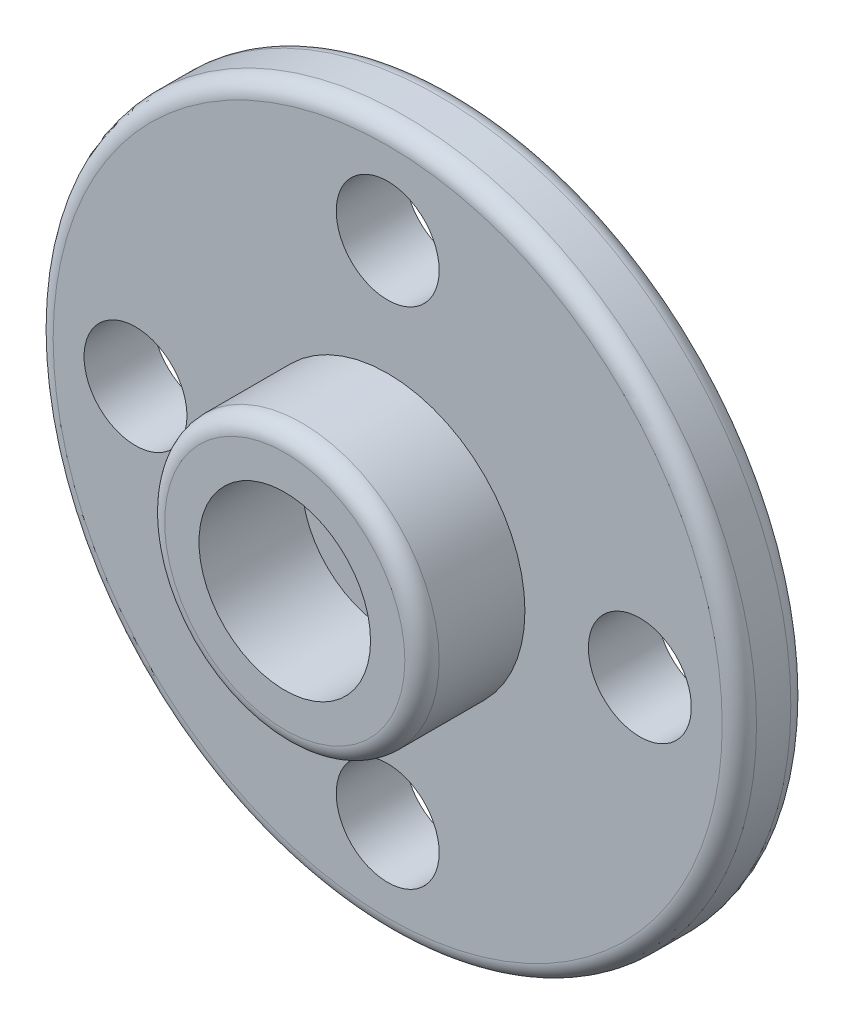
from build123d import *

# Parameters (mm, degrees)
SKETCH_1_R          = 10.25
SKETCH_1_R_2        = 1.5
EXTRUDE_1_DEPTH     = 2
SKETCH_2_R          = 4
EXTRUDE_2_DEPTH     = 3
SKETCH_3_R          = 2.5
CUT_EXTRUDE_1_DEPTH = 3
FILLET_1_R          = 0.5
FILLET_2_R          = 0.5
FILLET_3_R          = 0.5


with BuildPart() as part:
    # 草图1 → 凸台-拉伸1 (new body)
    with BuildSketch(Plane.XY):
        Circle(SKETCH_1_R)
        Circle(SKETCH_1_R_2, mode=Mode.SUBTRACT)
        with Locations((-7.35, 0)):
            Circle(SKETCH_1_R_2, mode=Mode.SUBTRACT)
        with Locations((7.35, 0)):
            Circle(SKETCH_1_R_2, mode=Mode.SUBTRACT)
        with Locations((0, 7.35)):
            Circle(SKETCH_1_R_2, mode=Mode.SUBTRACT)
        with Locations((0, -7.35)):
            Circle(SKETCH_1_R_2, mode=Mode.SUBTRACT)
    extrude(amount=EXTRUDE_1_DEPTH)

    # 草图2 → 凸台-拉伸2 (add)
    with BuildSketch(Plane.XY.offset(2)):
        Circle(SKETCH_2_R)
    extrude(amount=EXTRUDE_2_DEPTH)

    # 草图3 → 切除-拉伸1 (cut)
    with BuildSketch(Plane.XY.offset(5)):
        Circle(SKETCH_3_R)
    extrude(amount=-CUT_EXTRUDE_1_DEPTH, mode=Mode.SUBTRACT)

    # 圆角1
    fillet_1_edges = [part.edges().sort_by_distance(p)[0] for p in [
        (-10.25, 0, 2),
    ]]
    fillet(fillet_1_edges, radius=FILLET_1_R)

    # 圆角2
    fillet_2_edges = [part.edges().sort_by_distance(p)[0] for p in [
        (-10.25, 0, 0),
    ]]
    fillet(fillet_2_edges, radius=FILLET_2_R)

    # 圆角3
    fillet_3_edges = [part.edges().sort_by_distance(p)[0] for p in [
        (-4, 0, 5),
    ]]
    fillet(fillet_3_edges, radius=FILLET_3_R)


solid = part.part
